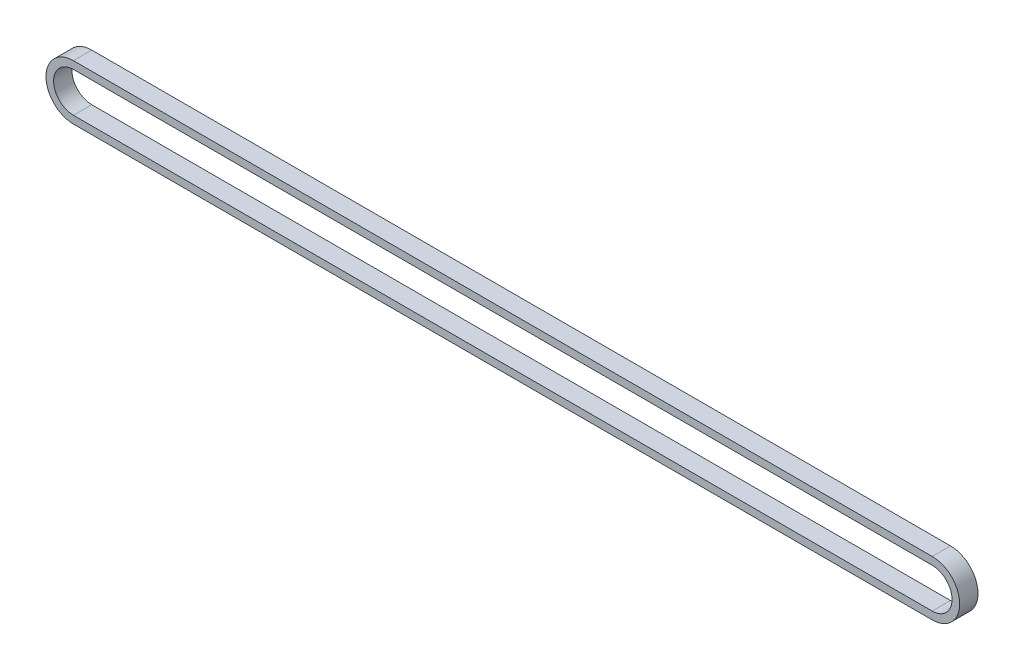
from build123d import *

# Parameters (mm, degrees)
BOSS_EXTRUDE1_DEPTH = 6


with BuildPart() as part:
    # Sketch2 → Boss-Extrude1 (new body)
    with BuildSketch(Plane.XY):
        with BuildLine():
            Line((-140.6652, 9), (140.6652, 9))
            ThreePointArc((140.6652, 9), (149.6652, 0), (140.6652, -9))
            Line((140.6652, -9), (-140.6652, -9))
            ThreePointArc((-140.6652, -9), (-149.6652, 0), (-140.6652, 9))
        make_face()
        with BuildLine():
            Line((-140.6652, 6.5), (140.6652, 6.5))
            ThreePointArc((140.6652, 6.5), (147.1652, 0), (140.6652, -6.5))
            Line((140.6652, -6.5), (-140.6652, -6.5))
            ThreePointArc((-140.6652, -6.5), (-147.1652, 0), (-140.6652, 6.5))
        make_face(mode=Mode.SUBTRACT)
    extrude(amount=BOSS_EXTRUDE1_DEPTH)


solid = part.part
